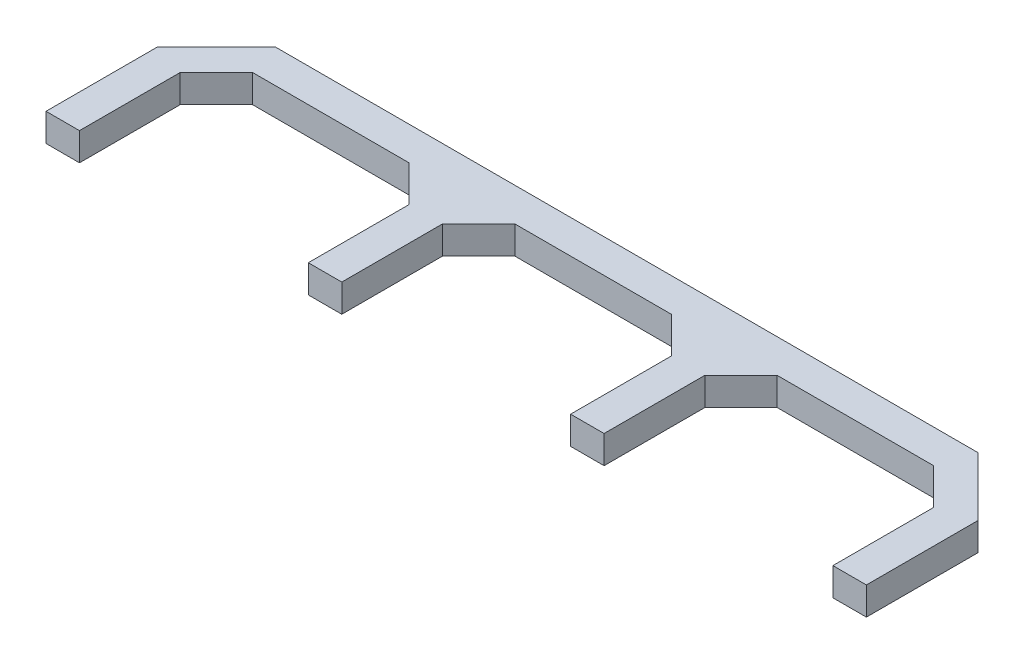
from build123d import *

# Parameters (mm, degrees)
BOSS_EXTRUDE1_DEPTH = 5


with BuildPart() as part:
    # Sketch1 → Boss-Extrude1 (new body)
    with BuildSketch(Plane(origin=(0, 0, 0), x_dir=(1, 0, 0), z_dir=(0, 1, 0))):
        Polygon((-38.794198113, 34.799835274), (-49.323631875, 24.270401512), (-49.323631875, 4.270401512), (-43.323631875, 4.270401512), (-43.323631875, 22.309848404), (-36.833645004, 28.799835274), (-8.813618745, 28.799835274), (-2.323631875, 22.309848404), (-2.323631875, 4.270401512), (3.676368125, 4.270401512), (3.676368125, 22.309848404), (10.166354996, 28.799835274), (38.186381255, 28.799835274), (44.676368125, 22.309848404), (44.676368125, 4.270401512), (50.676368125, 4.270401512), (50.676368125, 22.309848404), (57.166354996, 28.799835274), (85.186381255, 28.799835274), (91.676368125, 22.309848404), (91.676368125, 4.270401512), (97.676368125, 4.270401512), (97.676368125, 24.270401512), (87.146934364, 34.799835274), align=None)
    extrude(amount=BOSS_EXTRUDE1_DEPTH)


solid = part.part
